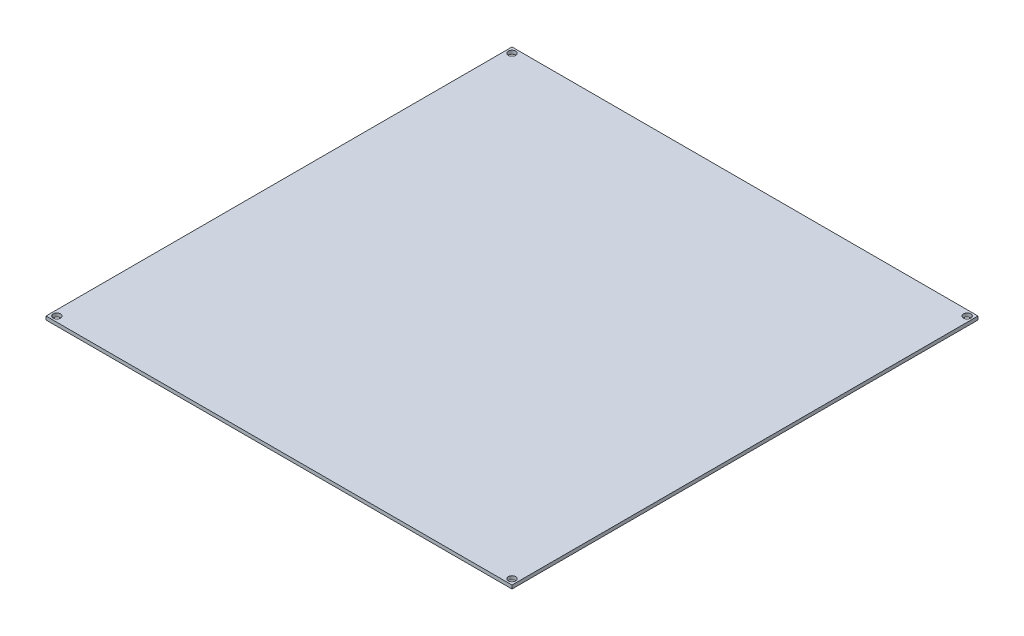
from build123d import *

# Parameters (mm, degrees)
SKETCH1_W                  = 214
SKETCH1_H                  = 214
BOSS_EXTRUDE1_DEPTH        = 1.6
F_3_4_3_4_DIAMETER_HOLE1_D = 3.4


with BuildPart() as part:
    # Sketch1 → Boss-Extrude1 (new body)
    with BuildSketch(Plane(origin=(0, 0, 0), x_dir=(1, 0, 0), z_dir=(0, 1, 0))):
        with Locations((107, 107)):
            Rectangle(SKETCH1_W, SKETCH1_H)
    extrude(amount=BOSS_EXTRUDE1_DEPTH)

    # Ø3.4 (3.4) Diameter Hole1 (through all)
    with Locations(Plane(origin=(0, 1.6, 0), x_dir=(1, 0, 0), z_dir=(0, 1, 0))):
        with Locations((2.5, 211.5), (211.5, 211.5), (211.5, 2.5), (2.5, 2.5)):
            Hole(F_3_4_3_4_DIAMETER_HOLE1_D / 2)


solid = part.part
